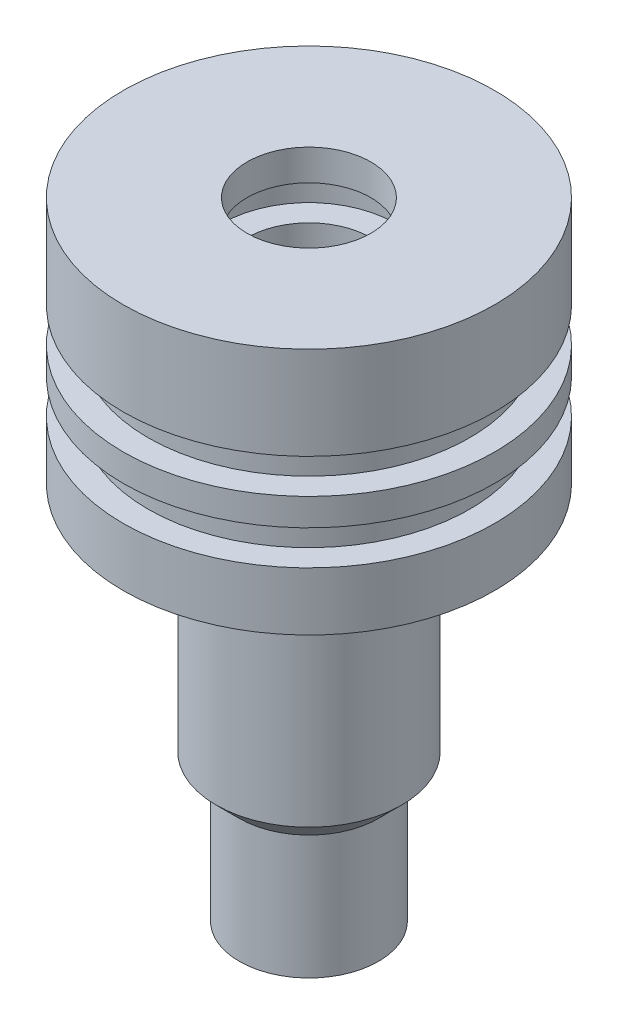
from build123d import *


with BuildPart() as part:
    # Sketch1 → Revolve1 (revolve)
    with BuildSketch(Plane.XY):
        Polygon((-6.35, -13.081), (-6.35, -64.29375), (-7.14375, -64.29375), (-7.14375, -51.59375), (-9.525, -49.2125), (-9.525, -25.4), (-19.05, -25.4), (-19.05, -19.431), (-16.51, -19.431), (-16.51, -15.875), (-19.05, -15.875), (-19.05, -13.081), (-16.51, -13.081), (-16.51, -9.525), (-19.05, -9.525), (-19.05, 0), (-6.35, 0), (-6.35, -3.175), (-8.89, -3.175), (-8.89, -6.731), (-6.35, -6.731), (-6.35, -9.525), (-8.89, -9.525), (-8.89, -13.081), align=None)
    revolve(axis=Axis((0, 0, 0), (0, -1, 0)))


solid = part.part
